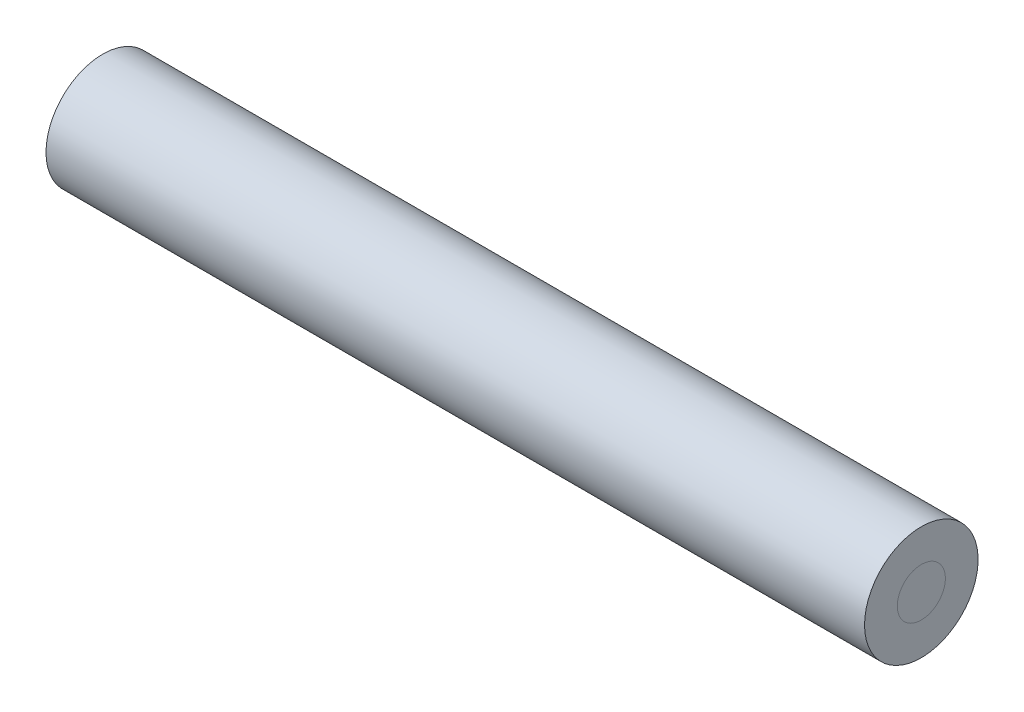
from build123d import *

# Parameters (mm, degrees)
SKETCH1_R           = 0.5969
BOSS_EXTRUDE1_DEPTH = 20.32
SKETCH1_3_R         = 1.4097
SKETCH1_3_R_2       = 0.5969
BOSS_EXTRUDE2_DEPTH = 20.32


with BuildPart() as part:
    # Sketch1 → Boss-Extrude1 (new body)
    with BuildSketch(Plane.ZY.offset(3.314620275)):
        with Locations((-16.770638736, 50.605756537)):
            Circle(SKETCH1_R)
    extrude(amount=BOSS_EXTRUDE1_DEPTH)


with BuildPart() as body_2:
    # Sketch1_3 → Boss-Extrude2 (new body)
    with BuildSketch(Plane.ZY.offset(3.314620275)):
        with Locations((-16.770638736, 50.605756537)):
            Circle(SKETCH1_3_R)
        with Locations((-16.770638736, 50.605756537)):
            Circle(SKETCH1_3_R_2, mode=Mode.SUBTRACT)
    extrude(amount=BOSS_EXTRUDE2_DEPTH)


solid = Compound([part.part, body_2.part])
